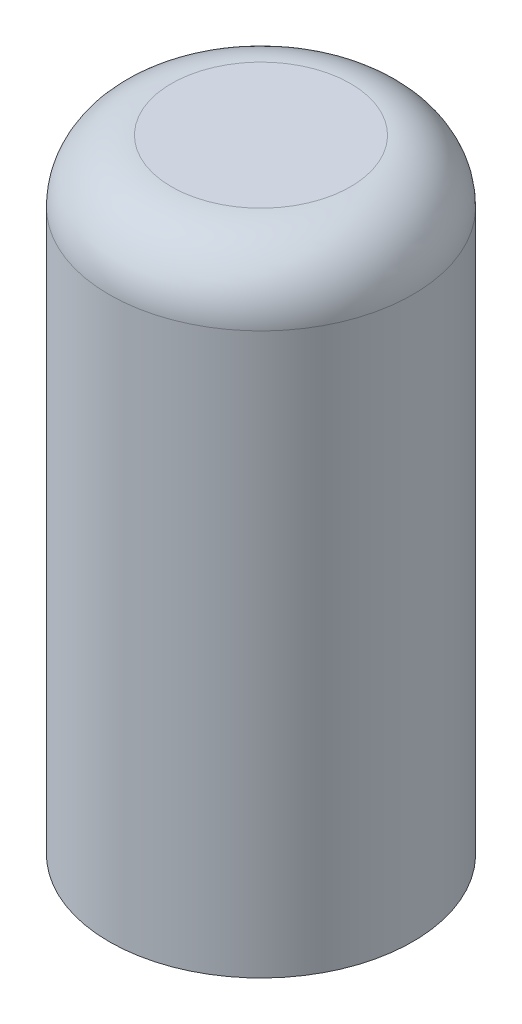
from build123d import *

# Parameters (mm, degrees)
SKETCH1_R           = 97.5
BOSS_EXTRUDE1_DEPTH = 650
SKETCH2_R           = 97.5
SKETCH2_R_2         = 67.5
CUT_EXTRUDE4_DEPTH  = 250
SKETCH4_R           = 67.5
CUT_EXTRUDE3_DEPTH  = 98.5
FILLET1_R           = 40
SKETCH5_R           = 67.5
CUT_EXTRUDE5_DEPTH  = 350


with BuildPart() as part:
    # Sketch1 → Boss-Extrude1 (new body)
    with BuildSketch(Plane(origin=(0, 0, 0), x_dir=(1, 0, 0), z_dir=(0, 1, 0))):
        Circle(SKETCH1_R)
    extrude(amount=BOSS_EXTRUDE1_DEPTH)

    # Sketch2 → Cut-Extrude4 (cut)
    with BuildSketch(Plane.XZ):
        Circle(SKETCH2_R)
        Circle(SKETCH2_R_2, mode=Mode.SUBTRACT)
    extrude(amount=-CUT_EXTRUDE4_DEPTH, mode=Mode.SUBTRACT)

    # Sketch4 → Cut-Extrude3 (cut, through all)
    with BuildSketch(Plane.XY):
        with Locations((0, 450)):
            Circle(SKETCH4_R)
    extrude(amount=-CUT_EXTRUDE3_DEPTH, mode=Mode.SUBTRACT)

    # Fillet1
    fillet1_edges = [part.edges().sort_by_distance(p)[0] for p in [
        (-97.5, 650, 0),
    ]]
    fillet(fillet1_edges, radius=FILLET1_R)

    # Sketch5 → Cut-Extrude5 (cut)
    with BuildSketch(Plane.XZ):
        Circle(SKETCH5_R)
    extrude(amount=-CUT_EXTRUDE5_DEPTH, mode=Mode.SUBTRACT)


solid = part.part
